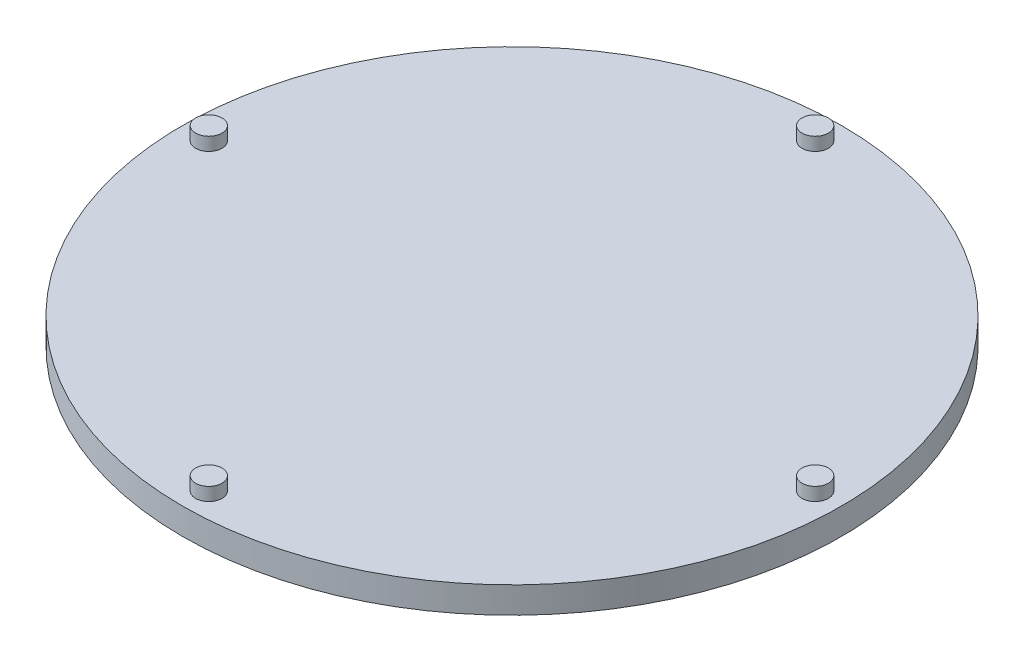
from build123d import *

# Parameters (mm, degrees)
SKETCH1_R           = 25
BOSS_EXTRUDE1_DEPTH = 2
SKETCH2_R           = 1
BOSS_EXTRUDE2_DEPTH = 1


with BuildPart() as part:
    # Sketch1 → Boss-Extrude1 (new body)
    with BuildSketch(Plane(origin=(0, 0, 0), x_dir=(1, 0, 0), z_dir=(0, 1, 0))):
        Circle(SKETCH1_R)
    extrude(amount=BOSS_EXTRUDE1_DEPTH)

    # Sketch2 → Boss-Extrude2 (add)
    with BuildSketch(Plane(origin=(0, 2, 0), x_dir=(1, 0, 0), z_dir=(0, 1, 0))):
        with Locations((0, 23)):
            Circle(SKETCH2_R)
        with Locations((23, 0)):
            Circle(SKETCH2_R)
        with Locations((0, -23)):
            Circle(SKETCH2_R)
        with Locations((-23, 0)):
            Circle(SKETCH2_R)
    extrude(amount=BOSS_EXTRUDE2_DEPTH)


solid = part.part
